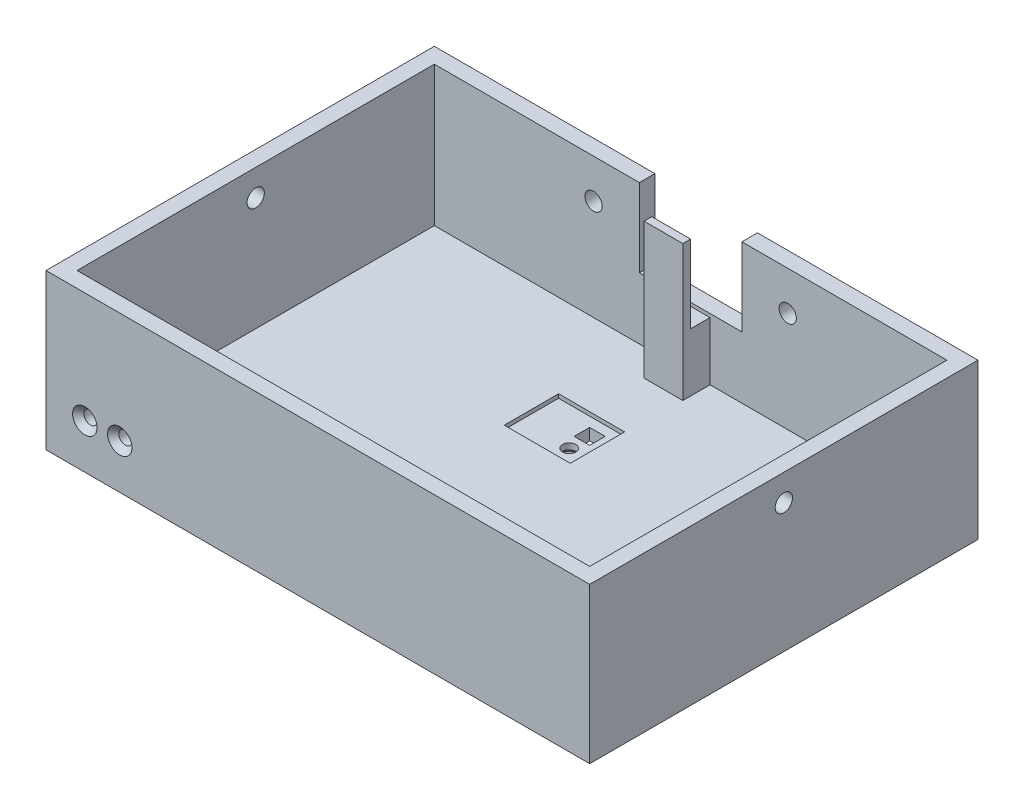
from build123d import *

# Parameters (mm, degrees)
SKETCH_1_W                  = 140
SKETCH_1_H                  = 100
SKETCH_1_W_2                = 132
SKETCH_1_H_2                = 92
EXTRUDE_2_DEPTH             = 4
EXTRUDE_3_DEPTH             = 2
EXTRUDE_START               = 4
SKETCH_1_6_W                = 140
SKETCH_1_6_H                = 100
SKETCH_1_6_W_2              = 132
SKETCH_1_6_H_2              = 92
EXTRUDE_4_DEPTH             = 36
HOLE_WIZARD_M31_D           = 3.4
HOLE_WIZARD_M31_DEPTH       = 4
HOLE_WIZARD_M31_CSINK_D     = 6.3
HOLE_WIZARD_M31_CSINK_ANGLE = 90
CUT_EXTRUDE_1_REACH         = 155.948
SKETCH_6_R                  = 2.225
CUT_EXTRUDE_3_REACH         = 130.452
SKETCH_7_W                  = 26.4
SKETCH_7_H                  = 20.1
CUT_EXTRUDE_6_REACH         = 130.452
SKETCH_7_9_R                = 2.225
HOLE_WIZARD_M33_D           = 3.4
HOLE_WIZARD_M33_CSINK_D     = 6.3
HOLE_WIZARD_M33_CSINK_ANGLE = 90
CUT_EXTRUDE_8_REACH         = 96.868
SKETCH_15_W                 = 4
SKETCH_15_H                 = 4
CUT_EXTRUDE_9_REACH         = 99.868
CUT_EXTRUDE_START           = -3
SKETCH_15_4_W               = 17
SKETCH_15_4_H               = 14
SKETCH_15_4_W_2             = 4
SKETCH_15_4_H_2             = 4
EXTRUDE_START_2             = -4
SKETCH_20_W                 = 10
SKETCH_20_H                 = 5
SKETCH_20_H_2               = 2
EXTRUDE_7_DEPTH             = 15
EXTRUDE_START_3             = -19
SKETCH_20_3_W               = 10
SKETCH_20_3_H               = 2
EXTRUDE_8_DEPTH             = 20
SKETCH_21_W                 = 0.664850428
SKETCH_21_H                 = 3.704166666
CUT_EXTRUDE_10_DEPTH        = 1


with BuildPart() as part:
    # Эскиз1 → Бобышка-Вытянуть2 (new body)
    with BuildSketch(Plane(origin=(0, 0, 0), x_dir=(1, 0, 0), z_dir=(0, 1, 0))):
        Rectangle(SKETCH_1_W, SKETCH_1_H)
        Rectangle(SKETCH_1_W_2, SKETCH_1_H_2, mode=Mode.SUBTRACT)
        Polygon((66, -46), (66, 46), (-66, 46), (-66, -46), (-63, -46), (-63, -44.5), (-59.7, -44.5), (-59.7, -41.5), (-51.3, -41.5), (-51.3, -44.5), (-48, -44.5), (-48, -46), align=None)
    extrude(amount=EXTRUDE_2_DEPTH)

    # Эскиз1<5> → Бобышка-Вытянуть3 (add)
    with BuildSketch(Plane(origin=(0, 0, 0), x_dir=(1, 0, 0), z_dir=(0, 1, 0))):
        Polygon((-63, -46), (-48, -46), (-48, -44.5), (-51.3, -44.5), (-51.3, -44.8), (-59.7, -44.8), (-59.7, -44.5), (-63, -44.5), align=None)
    extrude(amount=EXTRUDE_3_DEPTH)

    # Эскиз1<6> → Бобышка-Вытянуть4 (add)
    with BuildSketch(Plane(origin=(0, 0, 0), x_dir=(1, 0, 0), z_dir=(0, 1, 0)).offset(EXTRUDE_START)):
        Rectangle(SKETCH_1_6_W, SKETCH_1_6_H)
        Rectangle(SKETCH_1_6_W_2, SKETCH_1_6_H_2, mode=Mode.SUBTRACT)
    extrude(amount=EXTRUDE_4_DEPTH)

    # Зенковка для винта с потайной головкой M31
    with Locations(Plane(origin=(-51, 11.5, 50), x_dir=(1, 0, 0), z_dir=(0, 0, 1))):
        with Locations((0, 0), (-9, 0)):
            CounterSinkHole(HOLE_WIZARD_M31_D / 2, HOLE_WIZARD_M31_CSINK_D / 2, depth=HOLE_WIZARD_M31_DEPTH, counter_sink_angle=HOLE_WIZARD_M31_CSINK_ANGLE)

    # Эскиз6 → Вырез-Вытянуть1 (cut, up to next)
    with BuildSketch(Plane(origin=(70, 0, 0), x_dir=(0, 0, -1), z_dir=(1, 0, 0)), mode=Mode.PRIVATE) as cut_extrude_1_sk1:
        with Locations((0, 33.2)):
            Circle(SKETCH_6_R)
    cut_extrude_1_tool1 = extrude(cut_extrude_1_sk1.sketch, amount=-CUT_EXTRUDE_1_REACH, mode=Mode.PRIVATE) & part.part
    cut_extrude_1 = cut_extrude_1_tool1.solids().sort_by_distance((70, 33.2, 0))[0]
    add(cut_extrude_1, mode=Mode.SUBTRACT)

    # Зеркальное отражение1: Вырез-Вытянуть1 across plane
    add(cut_extrude_1.mirror(Plane(origin=(0, 0, 0), x_dir=(0, 0, 1), z_dir=(1, 0, 0))), mode=Mode.SUBTRACT)

    # Эскиз7 → Вырез-Вытянуть3 (cut, up to next)
    with BuildSketch(Plane(origin=(0, 0, -50), x_dir=(-1, 0, 0), z_dir=(0, 0, -1)), mode=Mode.PRIVATE) as cut_extrude_3_sk1:
        with Locations((0, 29.95)):
            Rectangle(SKETCH_7_W, SKETCH_7_H)
    cut_extrude_3_tool1 = extrude(cut_extrude_3_sk1.sketch, amount=-CUT_EXTRUDE_3_REACH, mode=Mode.PRIVATE) & part.part
    add(cut_extrude_3_tool1.solids().sort_by_distance((0, 29.95, -50))[0], mode=Mode.SUBTRACT)

    # Эскиз7<9> → Вырез-Вытянуть6 (cut, up to next)
    with BuildSketch(Plane(origin=(0, 0, -50), x_dir=(-1, 0, 0), z_dir=(0, 0, -1)), mode=Mode.PRIVATE) as cut_extrude_6_sk1:
        with Locations((-25, 29.95)):
            Circle(SKETCH_7_9_R)
    cut_extrude_6_tool1 = extrude(cut_extrude_6_sk1.sketch, amount=-CUT_EXTRUDE_6_REACH, mode=Mode.PRIVATE) & part.part
    # Эскиз7<9> → Вырез-Вытянуть6 (cut, up to next)
    with BuildSketch(Plane(origin=(0, 0, -50), x_dir=(-1, 0, 0), z_dir=(0, 0, -1)), mode=Mode.PRIVATE) as cut_extrude_6_sk2:
        with Locations((25, 29.95)):
            Circle(SKETCH_7_9_R)
    cut_extrude_6_tool2 = extrude(cut_extrude_6_sk2.sketch, amount=-CUT_EXTRUDE_6_REACH, mode=Mode.PRIVATE) & part.part
    add(cut_extrude_6_tool1.solids().sort_by_distance((25, 29.95, -50))[0], mode=Mode.SUBTRACT)
    add(cut_extrude_6_tool2.solids().sort_by_distance((-25, 29.95, -50))[0], mode=Mode.SUBTRACT)

    # Зенковка для винта с потайной головкой M33 (through all)
    with Locations(Plane(origin=(0, 0, -14.7), x_dir=(0, 0, -1), z_dir=(0, -1, 0))):
        with Locations((0, 0)):
            CounterSinkHole(HOLE_WIZARD_M33_D / 2, HOLE_WIZARD_M33_CSINK_D / 2, counter_sink_angle=HOLE_WIZARD_M33_CSINK_ANGLE)

    # Эскиз15 → Вырез-Вытянуть8 (cut, up to next)
    with BuildSketch(Plane.XZ, mode=Mode.PRIVATE) as cut_extrude_8_sk1:
        with Locations((0, -20)):
            Rectangle(SKETCH_15_W, SKETCH_15_H)
    cut_extrude_8_tool1 = extrude(cut_extrude_8_sk1.sketch, amount=-CUT_EXTRUDE_8_REACH, mode=Mode.PRIVATE) & part.part
    add(cut_extrude_8_tool1.solids().sort_by_distance((0, 0, -20))[0], mode=Mode.SUBTRACT)

    # Эскиз15<4> → Вырез-Вытянуть9 (cut, up to next)
    with BuildSketch(Plane.XZ.offset(CUT_EXTRUDE_START), mode=Mode.PRIVATE) as cut_extrude_9_sk1:
        with Locations((-4, -17.5)):
            Rectangle(SKETCH_15_4_W, SKETCH_15_4_H)
        with Locations((0, -20)):
            Rectangle(SKETCH_15_4_W_2, SKETCH_15_4_H_2, mode=Mode.SUBTRACT)
    cut_extrude_9_tool1 = extrude(cut_extrude_9_sk1.sketch, amount=-CUT_EXTRUDE_9_REACH, mode=Mode.PRIVATE) & part.part
    add(cut_extrude_9_tool1.solids().sort_by_distance((-4.288288, 3, -17.31982))[0], mode=Mode.SUBTRACT)

    # Эскиз20 → Бобышка-Вытянуть7 (add)
    with BuildSketch(Plane.XZ.offset(EXTRUDE_START_2)):
        with Locations((0, -43.5)):
            Rectangle(SKETCH_20_W, SKETCH_20_H)
        with Locations((0, -40)):
            Rectangle(SKETCH_20_W, SKETCH_20_H_2)
    extrude(amount=-EXTRUDE_7_DEPTH)

    # Эскиз20<3> → Бобышка-Вытянуть8 (add)
    with BuildSketch(Plane.XZ.offset(EXTRUDE_START_3)):
        with Locations((0, -40)):
            Rectangle(SKETCH_20_3_W, SKETCH_20_3_H)
    extrude(amount=-EXTRUDE_8_DEPTH)

    # Эскиз21 → Вырез-Вытянуть10 (cut)
    with BuildSketch(Plane.XZ):
        Polygon((-7.360844017, 26.295833333), (-8.100638522, 26.295833333), (-8.761778846, 27.595111345), (-9.422919171, 26.295833333), (-10.162713675, 26.295833333), (-9.09420406, 28.395751536), (-9.09420406, 30), (-8.429353632, 30), (-8.429353632, 28.395751536), align=None)
        with BuildLine():
            Line((-4.67769765, 30), (-4.67769765, 26.295833333))
            Line((-4.67769765, 26.295833333), (-5.271314103, 26.295833333))
            add(Edge.make_bspline(
                [(-5.271314103, 26.295833333), (-5.31287104, 26.29582766), (-5.393282926, 26.295816683), (-5.509295092, 26.299903172), (-5.616644377, 26.305119252), (-5.715461788, 26.311150817), (-5.805710741, 26.321160915), (-5.887453392, 26.331933671), (-5.960386991, 26.344839118), (-6.005477322, 26.356423188), (-6.026691039, 26.361873164)],
                knots=[0, 0, 0, 0, 1.311970222, 2.538637508, 3.664491357, 4.705491327, 5.663608299, 6.530571107, 7.308675535, 8, 8, 8, 8], degree=3))
            add(Edge.make_bspline(
                [(-6.026691039, 26.361873164), (-6.054546615, 26.369560182), (-6.109208197, 26.384644579), (-6.187505155, 26.415102656), (-6.261764836, 26.448979565), (-6.331971001, 26.48755156), (-6.397293339, 26.531538006), (-6.458627281, 26.580099943), (-6.515687524, 26.633253783), (-6.567564548, 26.691314468), (-6.614388963, 26.752752651), (-6.655239972, 26.817596967), (-6.690526167, 26.884819689), (-6.717620988, 26.955580973), (-6.740373771, 27.028032846), (-6.755595868, 27.103646953), (-6.765809559, 27.181771929), (-6.766750122, 27.234950154), (-6.767227564, 27.261944111)],
                knots=[0, 0, 0, 0, 1.099879008, 2.158315707, 3.195196496, 4.207130292, 5.205157476, 6.190838564, 7.183874245, 8.171129509, 9.152705923, 10.122275948, 11.08707516, 12.038677937, 13.004120747, 13.975884785, 14.972532894, 16, 16, 16, 16], degree=3))
            add(Edge.make_bspline(
                [(-6.767227564, 27.261944111), (-6.76606929, 27.296642989), (-6.763788001, 27.364984441), (-6.746281055, 27.464900878), (-6.718067585, 27.559857826), (-6.67819946, 27.650677442), (-6.624678653, 27.737222193), (-6.557936859, 27.821133851), (-6.476313973, 27.901266692), (-6.414743342, 27.950351077), (-6.382860911, 27.975767895)],
                knots=[0, 0, 0, 0, 0.986462413, 1.942894939, 2.875435142, 3.798266677, 4.755009598, 5.761362919, 6.840791609, 8, 8, 8, 8], degree=3))
            add(Edge.make_bspline(
                [(-6.382860911, 27.975767895), (-6.408979822, 27.989097155), (-6.460191781, 28.015232146), (-6.532852683, 28.058239537), (-6.600297973, 28.103797407), (-6.662059563, 28.151835509), (-6.719599834, 28.201400191), (-6.769346127, 28.255527376), (-6.816213212, 28.310039174), (-6.856337282, 28.368448582), (-6.891028514, 28.42950758), (-6.921804296, 28.492525813), (-6.946942144, 28.558756422), (-6.968581336, 28.627252077), (-6.984979225, 28.698720449), (-6.995584602, 28.772715956), (-7.003720801, 28.849195216), (-7.004352804, 28.901291794), (-7.004674145, 28.927780282)],
                knots=[0, 0, 0, 0, 1.164301211, 2.282872552, 3.350830854, 4.394111106, 5.389302619, 6.362088852, 7.310365691, 8.24222091, 9.170601078, 10.097577168, 11.024240953, 11.981127157, 12.948542686, 13.932080445, 14.948567018, 16, 16, 16, 16], degree=3))
            add(Edge.make_bspline(
                [(-7.004674145, 28.927780282), (-7.002692802, 28.978397696), (-6.998780658, 29.078341299), (-6.96712433, 29.224518762), (-6.916596092, 29.36381475), (-6.84574944, 29.493996255), (-6.759425249, 29.61275297), (-6.660581223, 29.717639041), (-6.549120308, 29.805474765), (-6.446974469, 29.865364426), (-6.358155382, 29.905297616), (-6.284285354, 29.929765961), (-6.20499898, 29.952445355), (-6.119408383, 29.970015998), (-6.027940433, 29.983108035), (-5.930636934, 29.992646338), (-5.827162295, 29.99866195), (-5.756109363, 29.999544966), (-5.719494525, 30)],
                knots=[0, 0, 0, 0, 1.284225818, 2.535691644, 3.779474941, 5.035581115, 6.285533147, 7.498311102, 8.683187976, 9.876672238, 10.49522506, 11.152635743, 11.850557634, 12.588370465, 13.369094102, 14.195874568, 15.07030211, 16, 16, 16, 16], degree=3))
            Line((-5.719494525, 30), (-4.67769765, 30))
        make_face()
        with BuildLine():
            Line((-5.342548077, 26.960683761), (-5.342548077, 27.768002137))
            Line((-5.342548077, 27.768002137), (-5.519148972, 27.768002137))
            add(Edge.make_bspline(
                [(-5.519148972, 27.768002137), (-5.543150918, 27.767793787), (-5.589485222, 27.767391581), (-5.656405391, 27.762174814), (-5.718647736, 27.753340305), (-5.776129913, 27.740752532), (-5.829187703, 27.725499305), (-5.877192725, 27.70609866), (-5.920300863, 27.682950654), (-5.97109283, 27.649311019), (-6.023411598, 27.597796057), (-6.070260271, 27.525078967), (-6.097716924, 27.440911558), (-6.100790162, 27.381609366), (-6.102377137, 27.350986579)],
                knots=[0, 0, 0, 0, 1.06517797, 2.056261606, 2.976983468, 3.853439442, 4.666321732, 5.424739265, 6.146762548, 6.834937974, 8.123729748, 9.372478121, 10.64318598, 12, 12, 12, 12], degree=3))
            add(Edge.make_bspline(
                [(-6.102377137, 27.350986579), (-6.101107736, 27.322301724), (-6.0986534, 27.266840711), (-6.07098899, 27.188915267), (-6.02789325, 27.120216444), (-5.977780501, 27.072519042), (-5.92999461, 27.040450445), (-5.888860674, 27.019067359), (-5.843656126, 27.000080932), (-5.793272027, 26.986822794), (-5.739218145, 26.974378655), (-5.680330231, 26.966811946), (-5.617204196, 26.961226635), (-5.57357826, 26.9608686), (-5.551055856, 26.960683761)],
                knots=[0, 0, 0, 0, 1.347812291, 2.605940898, 3.848830773, 5.144272192, 5.83350599, 6.558918059, 7.32804622, 8.140548749, 9.012446266, 9.943019774, 10.938059685, 12, 12, 12, 12], degree=3))
            Line((-5.551055856, 26.960683761), (-5.342548077, 26.960683761))
        make_face(mode=Mode.SUBTRACT)
        with BuildLine():
            Line((-5.342548077, 28.385363248), (-5.342548077, 29.335149573))
            Line((-5.342548077, 29.335149573), (-5.533989383, 29.335149573))
            add(Edge.make_bspline(
                [(-5.533989383, 29.335149573), (-5.571836642, 29.334929454), (-5.644602721, 29.334506248), (-5.748854794, 29.329534528), (-5.843594627, 29.320313304), (-5.928844514, 29.309547079), (-6.003906665, 29.292523899), (-6.070151968, 29.274824174), (-6.1264325, 29.252057352), (-6.17370873, 29.225655995), (-6.213247633, 29.195791329), (-6.247485595, 29.163470084), (-6.276042616, 29.127354439), (-6.299008818, 29.08824331), (-6.31830134, 29.046497592), (-6.330119516, 29.000731595), (-6.339075358, 28.952368581), (-6.339570425, 28.918921985), (-6.339823718, 28.901809562)],
                knots=[0, 0, 0, 0, 1.753677247, 3.371663338, 4.833688836, 6.164395063, 7.349095089, 8.3975697, 9.338276771, 10.154261968, 10.899224605, 11.628775934, 12.330426574, 13.024264642, 13.727131073, 14.452891561, 15.208446408, 16, 16, 16, 16], degree=3))
            add(Edge.make_bspline(
                [(-6.339823718, 28.901809562), (-6.339267862, 28.88224015), (-6.338185204, 28.844124201), (-6.329314979, 28.78842355), (-6.31326656, 28.73638578), (-6.292737226, 28.686661361), (-6.265021063, 28.640606417), (-6.231164445, 28.597914337), (-6.191468328, 28.558459282), (-6.145807334, 28.521643116), (-6.092791868, 28.488572661), (-6.031202431, 28.461825413), (-5.962630199, 28.437695864), (-5.885732735, 28.419043462), (-5.801112201, 28.403045041), (-5.708035099, 28.393532236), (-5.607311669, 28.386443148), (-5.537466849, 28.385731394), (-5.501340478, 28.385363248)],
                knots=[0, 0, 0, 0, 0.844862234, 1.645564352, 2.426138401, 3.19188377, 3.963047654, 4.738710309, 5.53926994, 6.37496817, 7.267116735, 8.227971149, 9.268346748, 10.402975021, 11.641070045, 12.984514716, 14.440277492, 16, 16, 16, 16], degree=3))
            Line((-5.501340478, 28.385363248), (-5.342548077, 28.385363248))
        make_face(mode=Mode.SUBTRACT)
        Polygon((-0.593616453, 26.295833333), (-2.588167735, 26.295833333), (-2.588167735, 26.960683761), (-1.25846688, 26.960683761), (-1.25846688, 27.673023504), (-2.588167735, 27.673023504), (-2.588167735, 28.337873932), (-1.25846688, 28.337873932), (-1.25846688, 29.335149573), (-2.588167735, 29.335149573), (-2.588167735, 30), (-0.593616453, 30), align=None)
        with BuildLine():
            Line((3.015571581, 26.295833333), (2.177830362, 26.295833333))
            add(Edge.make_bspline(
                [(2.177830362, 26.295833333), (2.112517208, 26.296279346), (1.986266142, 26.297141494), (1.803379182, 26.30722713), (1.633190412, 26.322037433), (1.476084825, 26.344703935), (1.331496675, 26.371011955), (1.200493246, 26.406243982), (1.082008378, 26.446675766), (0.974798578, 26.493784373), (0.877193779, 26.549031863), (0.785172007, 26.611100127), (0.697670919, 26.680920335), (0.614205601, 26.758655019), (0.534572647, 26.843787324), (0.460641374, 26.938031461), (0.390041599, 27.03894638), (0.323918809, 27.146882332), (0.265061267, 27.261626225), (0.212671457, 27.381372071), (0.169021282, 27.506197699), (0.13347976, 27.635930755), (0.105168974, 27.770195435), (0.085355478, 27.909247561), (0.073107843, 28.052962573), (0.07186533, 28.150365134), (0.071233974, 28.199858106)],
                knots=[0, 0, 0, 0, 1.44349102, 2.790284463, 4.047513061, 5.218094321, 6.297837468, 7.293772999, 8.213586047, 9.062895527, 9.878013142, 10.689252941, 11.514048747, 12.349645483, 13.208421871, 14.087867281, 14.994836234, 15.929653487, 16.883274053, 17.843080533, 18.816554169, 19.803369425, 20.81449504, 21.847452076, 22.906230055, 24, 24, 24, 24], degree=3))
            add(Edge.make_bspline(
                [(0.071233974, 28.199858106), (0.072887037, 28.269696003), (0.076141188, 28.407175991), (0.103555301, 28.608925044), (0.147885975, 28.802326415), (0.210244162, 28.985844916), (0.287464039, 29.157926595), (0.379944374, 29.315124356), (0.485028616, 29.457758629), (0.603649263, 29.583462816), (0.731883678, 29.69216878), (0.865667065, 29.784182979), (1.004879735, 29.858041143), (1.127803931, 29.904163618), (1.234694759, 29.933151783), (1.328404927, 29.949991966), (1.435055199, 29.965610546), (1.555047536, 29.979035128), (1.688737769, 29.988228315), (1.83571191, 29.994576859), (1.996005557, 29.999294231), (2.107334607, 29.999758579), (2.165216012, 30)],
                knots=[0, 0, 0, 0, 1.315347898, 2.589339334, 3.828278609, 5.048487211, 6.235212834, 7.375728391, 8.47833097, 9.56625089, 10.624194351, 11.640157642, 12.619895326, 13.585848527, 14.106971868, 14.704705962, 15.37825295, 16.137840974, 16.978850452, 17.902510282, 18.909488129, 20, 20, 20, 20], degree=3))
            Line((2.165216012, 30), (3.015571581, 30))
            Line((3.015571581, 30), (3.015571581, 26.295833333))
        make_face()
        with BuildLine():
            Line((2.350721154, 26.960683761), (2.350721154, 29.335149573))
            Line((2.350721154, 29.335149573), (2.003455529, 29.335149573))
            add(Edge.make_bspline(
                [(2.003455529, 29.335149573), (1.962143416, 29.334949523), (1.882698503, 29.334564818), (1.767857898, 29.329279022), (1.661875638, 29.320695518), (1.564612902, 29.307999222), (1.47584609, 29.292722328), (1.395898998, 29.273826825), (1.324614054, 29.250848453), (1.26140341, 29.22376821), (1.203693487, 29.192850105), (1.150229912, 29.156747291), (1.098631039, 29.116625617), (1.049850562, 29.071341384), (1.003706716, 29.021484388), (0.96047237, 28.966800313), (0.919567981, 28.907455897), (0.882054014, 28.843135016), (0.847741196, 28.774526831), (0.817426711, 28.702257198), (0.791835736, 28.625932135), (0.772401883, 28.545585428), (0.755846802, 28.461715662), (0.743892763, 28.37378358), (0.737380162, 28.282076463), (0.736520533, 28.219655142), (0.736084402, 28.187985777)],
                knots=[0, 0, 0, 0, 1.502729547, 2.8898115, 4.181010027, 5.369596896, 6.45687185, 7.456390247, 8.355533714, 9.177830239, 9.954819978, 10.733423081, 11.521791071, 12.330436719, 13.151797389, 13.990712567, 14.864234656, 15.771624029, 16.697123225, 17.652960569, 18.620374037, 19.622036587, 20.657870943, 21.729319508, 22.8479736, 24, 24, 24, 24], degree=3))
            add(Edge.make_bspline(
                [(0.736084402, 28.187985777), (0.736967187, 28.13945709), (0.73868855, 28.044829909), (0.75539277, 27.907021755), (0.782308144, 27.777417158), (0.821516404, 27.656349058), (0.869732311, 27.543047772), (0.931039844, 27.438973329), (1.001714565, 27.342419836), (1.057634518, 27.285788843), (1.085576088, 27.257491987)],
                knots=[0, 0, 0, 0, 1.138242922, 2.219485503, 3.251901297, 4.239342788, 5.201071, 6.134757343, 7.067992642, 8, 8, 8, 8], degree=3))
            add(Edge.make_bspline(
                [(1.085576088, 27.257491987), (1.113126827, 27.233378423), (1.169396092, 27.184129198), (1.268186429, 27.125116032), (1.377048264, 27.073267181), (1.49847203, 27.032156824), (1.631284219, 26.999645002), (1.776275864, 26.977222393), (1.932670503, 26.962813862), (2.041017064, 26.961409006), (2.09695012, 26.960683761)],
                knots=[0, 0, 0, 0, 0.813307809, 1.661089106, 2.549956539, 3.493439533, 4.508053171, 5.589449661, 6.755572447, 8, 8, 8, 8], degree=3))
            Line((2.09695012, 26.960683761), (2.350721154, 26.960683761))
        make_face(mode=Mode.SUBTRACT)
        Polygon((5.67423127, 26.295833333), (5.057612179, 26.295833333), (3.561698718, 30), (4.2718124, 30), (4.55971638, 29.24017094), (6.173611111, 29.24017094), (6.461515091, 30), (7.170886752, 30), align=None)
        Polygon((5.366292735, 27.289398872), (5.921324119, 28.575320513), (4.811261351, 28.575320513), align=None, mode=Mode.SUBTRACT)
        Polygon((11.128082432, 26.295833333), (10.438003305, 26.295833333), (9.59284188, 28.879548945), (8.741744291, 26.295833333), (8.058343349, 26.295833333), (7.432077991, 30), (8.105090645, 30), (8.500587607, 27.660409155), (9.270804955, 30), (9.919330929, 30), (10.685096154, 27.660409155), (11.079851095, 30), (11.753605769, 30), align=None)
        with Locations((-24.789423077, 35.369017094)):
            Rectangle(SKETCH_21_W, SKETCH_21_H)
        Polygon((-21.892574786, 33.516933761), (-23.887126068, 33.516933761), (-23.887126068, 34.181784188), (-22.557425214, 34.181784188), (-22.557425214, 34.894123932), (-23.887126068, 34.894123932), (-23.887126068, 35.558974359), (-22.557425214, 35.558974359), (-22.557425214, 36.55625), (-23.887126068, 36.55625), (-23.887126068, 37.221100427), (-21.892574786, 37.221100427), align=None)
        Polygon((-17.579209235, 33.516933761), (-18.269288361, 33.516933761), (-19.114449786, 36.100649372), (-19.965547376, 33.516933761), (-20.648948317, 33.516933761), (-21.275213675, 37.221100427), (-20.602201022, 37.221100427), (-20.20670406, 34.881509582), (-19.436486712, 37.221100427), (-18.787960737, 37.221100427), (-18.022195513, 34.881509582), (-17.627440572, 37.221100427), (-16.953685897, 37.221100427), align=None)
        with BuildLine():
            add(Edge.make_bspline(
                [(-14.705363582, 33.421955128), (-14.76976538, 33.423621928), (-14.896909117, 33.426912568), (-15.083886107, 33.454363303), (-15.264094619, 33.499038862), (-15.437560483, 33.561398748), (-15.603692097, 33.642160392), (-15.763099871, 33.740220734), (-15.915346963, 33.856411855), (-16.058658326, 33.989075704), (-16.190071338, 34.134139472), (-16.305584868, 34.288798347), (-16.403641213, 34.451455541), (-16.483233785, 34.622142746), (-16.545389843, 34.800625505), (-16.588587573, 34.986971553), (-16.616440445, 35.180942266), (-16.619636403, 35.313021049), (-16.621260684, 35.380147403)],
                knots=[0, 0, 0, 0, 1.014151002, 2.002163778, 2.969868608, 3.93493411, 4.9003771, 5.874719092, 6.87846472, 7.912488755, 8.947011879, 9.957751389, 10.948740761, 11.933621513, 12.919426746, 13.920294397, 14.943031967, 16, 16, 16, 16], degree=3))
            add(Edge.make_bspline(
                [(-16.621260684, 35.380147403), (-16.619530349, 35.446517269), (-16.616120669, 35.57730122), (-16.589728018, 35.769486236), (-16.545779498, 35.953829441), (-16.484821734, 36.130393858), (-16.406620854, 36.29918238), (-16.310062019, 36.459647309), (-16.195779624, 36.61211835), (-16.066108133, 36.755661408), (-15.924231793, 36.886803311), (-15.773065117, 37.001929792), (-15.614012522, 37.09876179), (-15.448090221, 37.179134426), (-15.273732924, 37.239532176), (-15.092873717, 37.28474007), (-14.903999662, 37.310881764), (-14.775686854, 37.314329205), (-14.710557726, 37.31607906)],
                knots=[0, 0, 0, 0, 1.051517626, 2.07204922, 3.067438659, 4.05042616, 5.027204762, 6.009981242, 7.012629434, 8.042243656, 9.071350414, 10.070091277, 11.048190212, 12.017682766, 12.985867053, 13.966945899, 14.968060614, 16, 16, 16, 16], degree=3))
            add(Edge.make_bspline(
                [(-14.710557726, 37.31607906), (-14.642435195, 37.314527756), (-14.508583734, 37.311479655), (-14.312642895, 37.282738127), (-14.125182194, 37.238917841), (-13.946715278, 37.17547661), (-13.777380883, 37.093043563), (-13.616419618, 36.99351195), (-13.465042054, 36.87495918), (-13.323752777, 36.740961007), (-13.195759261, 36.594299591), (-13.082775979, 36.439374679), (-12.987473054, 36.277357875), (-12.909845588, 36.108176448), (-12.848647277, 35.932881011), (-12.805478806, 35.750404179), (-12.779978163, 35.56118354), (-12.776426072, 35.432661101), (-12.774626068, 35.367533053)],
                knots=[0, 0, 0, 0, 1.067953136, 2.098381936, 3.099641766, 4.083805132, 5.062469929, 6.048665414, 7.046702845, 8.073106546, 9.098695993, 10.09591865, 11.076726721, 12.041940862, 13.011263376, 13.984305721, 14.978557872, 16, 16, 16, 16], degree=3))
            add(Edge.make_bspline(
                [(-12.774626068, 35.367533053), (-12.775198807, 35.323720211), (-12.776337033, 35.2366493), (-12.789747111, 35.10758116), (-12.809635896, 34.981217252), (-12.836863166, 34.857319954), (-12.873547352, 34.736208555), (-12.918134, 34.61757756), (-12.970091499, 34.501427624), (-13.030007529, 34.388809159), (-13.097784513, 34.281069585), (-13.170152046, 34.177267897), (-13.249881955, 34.080129095), (-13.335328582, 33.988598012), (-13.426826612, 33.903093059), (-13.524535401, 33.823322272), (-13.628301155, 33.749489113), (-13.737001511, 33.680983463), (-13.850264629, 33.620983157), (-13.965395767, 33.566597273), (-14.08350017, 33.522501213), (-14.20372032, 33.485979468), (-14.325779821, 33.456669284), (-14.450621079, 33.43718051), (-14.577190461, 33.423664491), (-14.662537815, 33.422526268), (-14.705363582, 33.421955128)],
                knots=[0, 0, 0, 0, 1.034641744, 2.056182551, 3.061960284, 4.05571729, 5.050247014, 6.048716841, 7.047801973, 8.054190544, 9.059424999, 10.053182006, 11.041513076, 12.025412457, 13.009311837, 13.997642908, 15.002928308, 16.016213968, 17.030509951, 18.02913364, 19.022134519, 20.005478534, 20.996155877, 21.984625117, 22.988721131, 24, 24, 24, 24], degree=3))
        make_face()
        with BuildLine():
            add(Edge.make_bspline(
                [(-14.694975294, 34.086805556), (-14.65163311, 34.087968525), (-14.566092984, 34.090263762), (-14.440621161, 34.107750318), (-14.320163918, 34.135678445), (-14.205388349, 34.176131607), (-14.0957994, 34.227619602), (-13.991193856, 34.289956296), (-13.893054206, 34.365308271), (-13.79994102, 34.449540014), (-13.71611224, 34.543781234), (-13.640738811, 34.643676397), (-13.579796335, 34.75162915), (-13.527394505, 34.864083821), (-13.488687649, 34.983884269), (-13.459216415, 35.109086142), (-13.443164433, 35.240974728), (-13.440723322, 35.330639804), (-13.439476496, 35.3764373)],
                knots=[0, 0, 0, 0, 1.033668485, 2.040047952, 3.016132939, 3.979056467, 4.937231767, 5.900589077, 6.877725736, 7.88429546, 8.891280164, 9.882584218, 10.863295226, 11.842887319, 12.837417301, 13.860812229, 14.907384602, 16, 16, 16, 16], degree=3))
            add(Edge.make_bspline(
                [(-13.439476496, 35.3764373), (-13.440992074, 35.427205361), (-13.443962357, 35.526702348), (-13.464557583, 35.671923679), (-13.500644433, 35.808913024), (-13.54994342, 35.938128658), (-13.615475835, 36.058211804), (-13.693854083, 36.17061827), (-13.787040584, 36.274650631), (-13.85870455, 36.335439662), (-13.895077123, 36.366292735)],
                knots=[0, 0, 0, 0, 1.078343132, 2.113373867, 3.107373148, 4.082093053, 5.043582658, 6.005574554, 6.987742499, 8, 8, 8, 8], degree=3))
            add(Edge.make_bspline(
                [(-13.895077123, 36.366292735), (-13.924881143, 36.389082186), (-13.983817693, 36.434147638), (-14.077893258, 36.491908259), (-14.174772566, 36.541414873), (-14.275186692, 36.581415632), (-14.378923567, 36.612879556), (-14.485968966, 36.634913225), (-14.596171214, 36.648741258), (-14.670695139, 36.65039397), (-14.708331664, 36.651228632)],
                knots=[0, 0, 0, 0, 1.023928204, 2.024787132, 3.009472467, 3.9914905, 4.972207045, 5.96565515, 6.972602802, 8, 8, 8, 8], degree=3))
            add(Edge.make_bspline(
                [(-14.708331664, 36.651228632), (-14.750927753, 36.650054138), (-14.834736898, 36.647743284), (-14.957884769, 36.630495759), (-15.075809444, 36.601178982), (-15.189603962, 36.561367862), (-15.297744529, 36.508014065), (-15.401917515, 36.444660522), (-15.500881357, 36.369331374), (-15.593429624, 36.28297692), (-15.678245163, 36.188731256), (-15.753283311, 36.08829577), (-15.815427269, 35.981666554), (-15.867263239, 35.870267945), (-15.907649232, 35.753212974), (-15.935287587, 35.630492815), (-15.953050228, 35.502602587), (-15.955276241, 35.41557718), (-15.956410256, 35.371243156)],
                knots=[0, 0, 0, 0, 1.026350473, 2.019376834, 2.989435443, 3.95094063, 4.91865229, 5.889827372, 6.885283771, 7.910196595, 8.935871797, 9.9372888, 10.925850568, 11.904605667, 12.894245083, 13.903507864, 14.931967858, 16, 16, 16, 16], degree=3))
            add(Edge.make_bspline(
                [(-15.956410256, 35.371243156), (-15.955241397, 35.327162246), (-15.952940676, 35.240395697), (-15.935596497, 35.112860252), (-15.906762389, 34.9908144), (-15.866010578, 34.873943537), (-15.815242302, 34.761634101), (-15.751468895, 34.654860841), (-15.676072678, 34.553716135), (-15.590431958, 34.458801301), (-15.49723263, 34.371574801), (-15.397169797, 34.295879545), (-15.293048117, 34.230102387), (-15.182477277, 34.178575311), (-15.06771979, 34.137523774), (-14.948075311, 34.107292839), (-14.823090705, 34.090386601), (-14.738061092, 34.088009878), (-14.694975294, 34.086805556)],
                knots=[0, 0, 0, 0, 1.055040155, 2.076685641, 3.074845078, 4.052329834, 5.035358467, 6.020382375, 7.023447318, 8.050688466, 9.077178457, 10.074336316, 11.0503314, 12.019748348, 12.988025369, 13.964577102, 14.968620271, 16, 16, 16, 16], degree=3))
        make_face(mode=Mode.SUBTRACT)
        Polygon((-10.495138889, 33.516933761), (-12.299732906, 33.516933761), (-12.299732906, 34.181784188), (-11.159989316, 34.181784188), (-11.159989316, 34.894123932), (-12.299732906, 34.894123932), (-12.299732906, 35.558974359), (-11.159989316, 35.558974359), (-11.159989316, 37.221100427), (-10.495138889, 37.221100427), align=None)
        with Locations((-9.307905983, 35.369017094)):
            Rectangle(SKETCH_21_W, SKETCH_21_H)
        Polygon((-6.553525641, 33.516933761), (-8.548076923, 33.516933761), (-8.548076923, 34.181784188), (-7.883226496, 34.181784188), (-7.883226496, 37.221100427), (-7.218376068, 37.221100427), (-7.218376068, 34.181784188), (-6.553525641, 34.181784188), align=None)
        with BuildLine():
            Line((-4.331916066, 35.754867788), (-4.748931624, 36.22827691))
            Line((-4.748931624, 36.22827691), (-4.558232338, 36.400425681))
            Line((-4.558232338, 36.400425681), (-4.369759115, 36.56960637))
            Line((-4.369759115, 36.56960637), (-4.962633547, 37.221100427))
            Line((-4.962633547, 37.221100427), (-4.11450404, 37.221100427))
            Line((-4.11450404, 37.221100427), (-3.872605335, 36.970297476))
            add(Edge.make_bspline(
                [(-3.872605335, 36.970297476), (-3.824823584, 36.993973181), (-3.731173812, 37.040376342), (-3.59012685, 37.101357759), (-3.451603407, 37.152619091), (-3.315922255, 37.195714531), (-3.181994097, 37.226968032), (-3.051146983, 37.251392421), (-2.922661039, 37.266034907), (-2.837769151, 37.267746334), (-2.795933494, 37.268589744)],
                knots=[0, 0, 0, 0, 1.134846175, 2.224240057, 3.268605059, 4.277623426, 5.251861872, 6.193569972, 7.109771376, 8, 8, 8, 8], degree=3))
            add(Edge.make_bspline(
                [(-2.795933494, 37.268589744), (-2.761526026, 37.267890707), (-2.694254804, 37.266523996), (-2.595857848, 37.255455057), (-2.502585165, 37.235919093), (-2.414229797, 37.209592751), (-2.331116956, 37.174948556), (-2.252699388, 37.133562708), (-2.179760621, 37.083469128), (-2.112507044, 37.026203326), (-2.050867996, 36.963951496), (-1.99831595, 36.895613508), (-1.952158379, 36.824425645), (-1.915932013, 36.747592991), (-1.886605088, 36.666985612), (-1.867235261, 36.581682902), (-1.853615766, 36.492627103), (-1.852602225, 36.431645659), (-1.852083333, 36.400425681)],
                knots=[0, 0, 0, 0, 1.146325904, 2.24122114, 3.293472846, 4.31812184, 5.308385844, 6.289138462, 7.267533498, 8.249981455, 9.229105173, 10.180360779, 11.117770178, 12.050384985, 13.00449251, 13.970029, 14.960738752, 16, 16, 16, 16], degree=3))
            add(Edge.make_bspline(
                [(-1.852083333, 36.400425681), (-1.853958588, 36.353038567), (-1.857693425, 36.258660348), (-1.887269611, 36.119438589), (-1.933919206, 35.983957512), (-1.989794753, 35.875716832), (-2.04338222, 35.790353753), (-2.091430023, 35.725744027), (-2.14543336, 35.660371755), (-2.207045857, 35.595149943), (-2.274129221, 35.528013928), (-2.349551491, 35.461930849), (-2.430131323, 35.393894624), (-2.487537974, 35.350451535), (-2.516933761, 35.328205963)],
                knots=[0, 0, 0, 0, 1.298575957, 2.586299866, 3.886292323, 5.218034109, 5.916202773, 6.6488126, 7.424377237, 8.240272888, 9.10843449, 10.02606486, 10.989222055, 12, 12, 12, 12], degree=3))
            add(Edge.make_bspline(
                [(-2.516933761, 35.328205963), (-2.486789799, 35.289966278), (-2.428437931, 35.215942927), (-2.351393476, 35.103003213), (-2.285634756, 34.993908571), (-2.231595265, 34.888214102), (-2.189696947, 34.785714894), (-2.159607732, 34.686422268), (-2.140716331, 34.590367358), (-2.138229023, 34.527149308), (-2.137019231, 34.496400908)],
                knots=[0, 0, 0, 0, 1.254783331, 2.428975762, 3.521264868, 4.536304978, 5.485798762, 6.371253184, 7.2077997, 8, 8, 8, 8], degree=3))
            add(Edge.make_bspline(
                [(-2.137019231, 34.496400908), (-2.137746568, 34.474096711), (-2.139210139, 34.429215472), (-2.150760555, 34.362258673), (-2.16969221, 34.295488472), (-2.195560044, 34.228783949), (-2.229358574, 34.162741125), (-2.269874432, 34.096624052), (-2.318160203, 34.031000724), (-2.373030478, 33.966114606), (-2.434905213, 33.90541779), (-2.503208763, 33.851552183), (-2.578194158, 33.806825223), (-2.659205845, 33.770396509), (-2.745861055, 33.741242638), (-2.839033793, 33.721769428), (-2.937767941, 33.708449123), (-3.00587808, 33.707419134), (-3.04080028, 33.706891026)],
                knots=[0, 0, 0, 0, 0.803898129, 1.617630241, 2.442092495, 3.303311795, 4.192745454, 5.11355102, 6.096443408, 7.127633651, 8.174554725, 9.216449452, 10.256510395, 11.314202351, 12.414104221, 13.545904242, 14.741708296, 16, 16, 16, 16], degree=3))
            add(Edge.make_bspline(
                [(-3.04080028, 33.706891026), (-3.075967573, 33.707424675), (-3.144566181, 33.708465632), (-3.244065787, 33.721715057), (-3.337576594, 33.741378673), (-3.424798886, 33.769405562), (-3.505384142, 33.80628261), (-3.580521906, 33.849777441), (-3.648161585, 33.90322545), (-3.709292712, 33.963154486), (-3.763315804, 34.026968145), (-3.810469649, 34.092099365), (-3.850817871, 34.157154233), (-3.883196023, 34.222714391), (-3.910273867, 34.287526425), (-3.92757484, 34.353505045), (-3.939451022, 34.419297827), (-3.94089822, 34.463454031), (-3.941613248, 34.4852706)],
                knots=[0, 0, 0, 0, 1.276613589, 2.490209188, 3.639193385, 4.744453696, 5.809999019, 6.853188294, 7.890207437, 8.932196598, 9.958377908, 10.92346682, 11.851109371, 12.735083872, 13.577633109, 14.397160969, 15.208073967, 16, 16, 16, 16], degree=3))
            add(Edge.make_bspline(
                [(-3.941613248, 34.4852706), (-3.940380217, 34.519511989), (-3.937928421, 34.587598587), (-3.916497154, 34.688199145), (-3.884123963, 34.786956173), (-3.844410872, 34.867749035), (-3.803253851, 34.934037485), (-3.763489369, 34.990135026), (-3.714423414, 35.051116728), (-3.656981624, 35.117924754), (-3.591602805, 35.190832952), (-3.517213385, 35.269346112), (-3.434334533, 35.353951633), (-3.3750995, 35.411209014), (-3.344286692, 35.440993089)],
                knots=[0, 0, 0, 0, 1.060773976, 2.109274582, 3.176545833, 4.277732972, 4.890795241, 5.595227009, 6.408622695, 7.317144787, 8.327436618, 9.445222173, 10.671058765, 12, 12, 12, 12], degree=3))
            add(Edge.make_bspline(
                [(-3.344286692, 35.440993089), (-3.380127531, 35.482566595), (-3.448253538, 35.561589214), (-3.545471268, 35.673623204), (-3.632436444, 35.77339038), (-3.709708591, 35.860856683), (-3.776570562, 35.936657197), (-3.83489443, 35.998853547), (-3.882218753, 36.049468984), (-3.910664968, 36.078912642), (-3.923062734, 36.091745126)],
                knots=[0, 0, 0, 0, 1.51243447, 2.87482453, 4.087181207, 5.159139051, 6.090728175, 6.871952111, 7.508360801, 8, 8, 8, 8], degree=3))
            add(Edge.make_bspline(
                [(-3.923062734, 36.091745126), (-3.930955974, 36.085533912), (-3.949385096, 36.071031984), (-3.981689176, 36.04687022), (-4.020643574, 36.014426087), (-4.068443056, 35.976276278), (-4.122738975, 35.930021291), (-4.185711242, 35.878059818), (-4.255890071, 35.818571113), (-4.305675984, 35.776854748), (-4.331916066, 35.754867788)],
                knots=[0, 0, 0, 0, 0.454982147, 1.062291435, 1.826978546, 2.750907302, 3.832570326, 5.057685674, 6.44922862, 8, 8, 8, 8], degree=3))
        make_face()
        with BuildLine():
            add(Edge.make_bspline(
                [(-2.9873748, 34.952743556), (-3.010088905, 34.933684727), (-3.053714991, 34.897079188), (-3.112855887, 34.841017678), (-3.163318436, 34.786946923), (-3.203636537, 34.733727366), (-3.236128459, 34.682634124), (-3.25950791, 34.632919711), (-3.273954816, 34.584517037), (-3.275847362, 34.552634289), (-3.276762821, 34.537212039)],
                knots=[0, 0, 0, 0, 1.365108641, 2.621910227, 3.750473504, 4.766462676, 5.692471511, 6.533310132, 7.290536163, 8, 8, 8, 8], degree=3))
            add(Edge.make_bspline(
                [(-3.276762821, 34.537212039), (-3.275865302, 34.522047131), (-3.274143095, 34.492947902), (-3.262007075, 34.451147055), (-3.2406074, 34.414548646), (-3.212227166, 34.382040412), (-3.17650848, 34.356422471), (-3.135300529, 34.337297871), (-3.088862358, 34.326231074), (-3.056194244, 34.324926266), (-3.039316239, 34.324252137)],
                knots=[0, 0, 0, 0, 1.016660416, 1.95082179, 2.886895472, 3.838707486, 4.824036216, 5.811038779, 6.869071653, 8, 8, 8, 8], degree=3))
            add(Edge.make_bspline(
                [(-3.039316239, 34.324252137), (-3.023403643, 34.325139362), (-2.992053444, 34.326887329), (-2.947073113, 34.339762429), (-2.906025436, 34.36106331), (-2.870022284, 34.390041), (-2.839734174, 34.424260727), (-2.817794662, 34.462658991), (-2.804469215, 34.503950905), (-2.802744665, 34.532415747), (-2.801869658, 34.546858307)],
                knots=[0, 0, 0, 0, 1.057994133, 2.084406969, 3.085568065, 4.116326501, 5.142871292, 6.108496369, 7.040284384, 8, 8, 8, 8], degree=3))
            add(Edge.make_bspline(
                [(-2.801869658, 34.546858307), (-2.8024565, 34.561989738), (-2.803658999, 34.592995587), (-2.813323016, 34.639916144), (-2.827523908, 34.688611607), (-2.847333395, 34.739092841), (-2.874989957, 34.790258926), (-2.906510886, 34.843514386), (-2.944070783, 34.898389132), (-2.97254283, 34.934126735), (-2.9873748, 34.952743556)],
                knots=[0, 0, 0, 0, 0.798403377, 1.636010132, 2.52046941, 3.476032658, 4.492491044, 5.587786094, 6.743403203, 8, 8, 8, 8], degree=3))
        make_face(mode=Mode.SUBTRACT)
        with BuildLine():
            add(Edge.make_bspline(
                [(-3.437781283, 36.476853799), (-3.419693129, 36.459326568), (-3.381257762, 36.422083102), (-3.321025205, 36.362317554), (-3.256629586, 36.29339988), (-3.186058175, 36.217264598), (-3.110684325, 36.132626323), (-3.029628911, 36.040304522), (-2.942762805, 35.940588992), (-2.884110318, 35.870480997), (-2.853811098, 35.834263989)],
                knots=[0, 0, 0, 0, 0.695851971, 1.478609945, 2.343846541, 3.301331317, 4.346617988, 5.474767113, 6.695492858, 8, 8, 8, 8], degree=3))
            add(Edge.make_bspline(
                [(-2.853811098, 35.834263989), (-2.827339971, 35.858983628), (-2.776442551, 35.90651337), (-2.707485847, 35.978827942), (-2.649087469, 36.048879343), (-2.600897119, 36.116186848), (-2.564325152, 36.182131517), (-2.536810817, 36.245178449), (-2.520310602, 36.306589129), (-2.51802983, 36.346913892), (-2.516933761, 36.366292735)],
                knots=[0, 0, 0, 0, 1.344929586, 2.585966416, 3.70798992, 4.729929545, 5.655146471, 6.503081986, 7.280627179, 8, 8, 8, 8], degree=3))
            add(Edge.make_bspline(
                [(-2.516933761, 36.366292735), (-2.518319407, 36.384011948), (-2.521089616, 36.419436531), (-2.540984809, 36.471359643), (-2.574604235, 36.519428516), (-2.619127014, 36.564117411), (-2.672162443, 36.603712485), (-2.734888478, 36.631072085), (-2.803601178, 36.648889336), (-2.851962217, 36.650434574), (-2.876813735, 36.651228632)],
                knots=[0, 0, 0, 0, 0.839037447, 1.677419396, 2.597629847, 3.600735691, 4.658333153, 5.713002508, 6.824769699, 8, 8, 8, 8], degree=3))
            add(Edge.make_bspline(
                [(-2.876813735, 36.651228632), (-2.896134324, 36.650583215), (-2.935921347, 36.649254103), (-2.997371842, 36.6403633), (-3.062455236, 36.627361052), (-3.130888555, 36.607451482), (-3.202743293, 36.583075914), (-3.278219773, 36.552991581), (-3.357194383, 36.517588076), (-3.410432869, 36.490677607), (-3.437781283, 36.476853799)],
                knots=[0, 0, 0, 0, 0.782485555, 1.611377918, 2.511278134, 3.469099476, 4.495613048, 5.58396865, 6.758893619, 8, 8, 8, 8], degree=3))
        make_face(mode=Mode.SUBTRACT)
        with BuildLine():
            Line((1.314860443, 37.31607906), (1.904024773, 37.019270833))
            Line((1.904024773, 37.019270833), (1.25846688, 35.748931624))
            add(Edge.make_bspline(
                [(1.25846688, 35.748931624), (1.296607864, 35.747959386), (1.371487844, 35.746050648), (1.481743772, 35.730191295), (1.587174987, 35.703112703), (1.689042542, 35.667083721), (1.785869493, 35.618710401), (1.879219358, 35.561167552), (1.966654697, 35.490975859), (2.050269542, 35.413256118), (2.125905575, 35.327119158), (2.192704846, 35.235083382), (2.249267826, 35.138034615), (2.294674208, 35.035320704), (2.330336574, 34.92796528), (2.356639511, 34.815547213), (2.371355685, 34.697634096), (2.373416635, 34.617389564), (2.374465812, 34.576539129)],
                knots=[0, 0, 0, 0, 1.014438208, 1.991587644, 2.955575466, 3.906834206, 4.860343588, 5.829907848, 6.818577787, 7.838125475, 8.863876483, 9.862937823, 10.859547262, 11.846397878, 12.845242478, 13.865236027, 14.913246352, 16, 16, 16, 16], degree=3))
            add(Edge.make_bspline(
                [(2.374465812, 34.576539129), (2.373494963, 34.536913393), (2.371581926, 34.458831699), (2.355651941, 34.34424573), (2.329539481, 34.23417815), (2.293278159, 34.128663242), (2.246338904, 34.027884756), (2.18837805, 33.932266081), (2.120953697, 33.84074871), (2.04320093, 33.755477974), (1.959039408, 33.677399776), (1.869077631, 33.609451961), (1.775637548, 33.55085372), (1.676716567, 33.50429898), (1.574122279, 33.466508387), (1.466496569, 33.440943187), (1.354924878, 33.42483521), (1.279052001, 33.422922837), (1.240658387, 33.421955128)],
                knots=[0, 0, 0, 0, 1.05547428, 2.079790231, 3.075662031, 4.065650429, 5.047466705, 6.031911617, 7.04026589, 8.071428158, 9.102169131, 10.094698886, 11.071325611, 12.035261792, 13.002593907, 13.979242867, 14.977445265, 16, 16, 16, 16], degree=3))
            add(Edge.make_bspline(
                [(1.240658387, 33.421955128), (1.200522348, 33.422781626), (1.121600258, 33.424406822), (1.00606522, 33.442328131), (0.895540183, 33.469847591), (0.789509066, 33.50713643), (0.689653926, 33.558011332), (0.594072109, 33.617777201), (0.504616041, 33.690151384), (0.420827081, 33.771573449), (0.345395384, 33.860889793), (0.278143759, 33.953609789), (0.220977716, 34.050019117), (0.175313598, 34.150184914), (0.139004495, 34.253418931), (0.114264302, 34.35994954), (0.097795997, 34.469672024), (0.095925363, 34.544076886), (0.094978632, 34.581733273)],
                knots=[0, 0, 0, 0, 1.062709067, 2.08967359, 3.089490552, 4.078335371, 5.060205664, 6.052952122, 7.060109841, 8.102908433, 9.144326257, 10.153805576, 11.135063239, 12.108674621, 13.066249871, 14.029571809, 15.002763993, 16, 16, 16, 16], degree=3))
            add(Edge.make_bspline(
                [(0.094978632, 34.581733273), (0.095498592, 34.610452263), (0.096545909, 34.668298766), (0.106715372, 34.75480974), (0.122357037, 34.841542993), (0.140598701, 34.914599297), (0.158947416, 34.976431057), (0.178027013, 35.028736249), (0.2010379, 35.087020853), (0.22767169, 35.151374564), (0.258142365, 35.221478582), (0.293488558, 35.297089278), (0.331477788, 35.379365249), (0.359484205, 35.435622786), (0.373978365, 35.464737747)],
                knots=[0, 0, 0, 0, 1.105166677, 2.22605417, 3.348517788, 4.496260522, 5.122810462, 5.830557215, 6.638607343, 7.535109037, 8.511576286, 9.580928918, 10.748058253, 12, 12, 12, 12], degree=3))
            Line((0.373978365, 35.464737747), (1.314860443, 37.31607906))
        make_face()
        with BuildLine():
            add(Edge.make_bspline(
                [(1.225817975, 35.131570513), (1.193958457, 35.129697993), (1.13171217, 35.126039514), (1.042344582, 35.097663982), (0.962043155, 35.049253924), (0.891604658, 34.984042078), (0.832967623, 34.905645114), (0.790001492, 34.816571813), (0.763952075, 34.718240743), (0.761229798, 34.649666701), (0.75982906, 34.614382178)],
                knots=[0, 0, 0, 0, 0.984989413, 1.924446292, 2.868477643, 3.865502828, 4.877610339, 5.88087679, 6.909612885, 8, 8, 8, 8], degree=3))
            add(Edge.make_bspline(
                [(0.75982906, 34.614382178), (0.761485122, 34.578350566), (0.76470656, 34.508260476), (0.791438257, 34.407634855), (0.835669685, 34.316102283), (0.897449901, 34.236767309), (0.970003108, 34.170917798), (1.050450083, 34.12221784), (1.137455724, 34.092300095), (1.197639428, 34.088649715), (1.228044037, 34.086805556)],
                knots=[0, 0, 0, 0, 1.10379546, 2.14714571, 3.168417875, 4.20176326, 5.211701457, 6.157576563, 7.069213742, 8, 8, 8, 8], degree=3))
            add(Edge.make_bspline(
                [(1.228044037, 34.086805556), (1.260178968, 34.088604332), (1.323275643, 34.092136216), (1.413840067, 34.121970289), (1.496948135, 34.169603772), (1.570624772, 34.235333308), (1.632910283, 34.314252583), (1.677198538, 34.405710907), (1.704957625, 34.50591414), (1.708034882, 34.576105362), (1.709615385, 34.612156116)],
                knots=[0, 0, 0, 0, 0.970853505, 1.906262912, 2.855477211, 3.852937491, 4.877462982, 5.878766514, 6.910518104, 8, 8, 8, 8], degree=3))
            add(Edge.make_bspline(
                [(1.709615385, 34.612156116), (1.707869301, 34.64766811), (1.704476449, 34.716672205), (1.679032341, 34.81616509), (1.63425699, 34.905553249), (1.574047989, 34.984351851), (1.501232902, 35.049548777), (1.417668418, 35.098044439), (1.324265107, 35.125979741), (1.259143995, 35.129677942), (1.225817975, 35.131570513)],
                knots=[0, 0, 0, 0, 1.075564157, 2.089951178, 3.085472164, 4.085356838, 5.078137244, 6.028240785, 6.99094342, 8, 8, 8, 8], degree=3))
        make_face(mode=Mode.SUBTRACT)
        Polygon((4.684375835, 33.516933761), (3.65667735, 33.516933761), (3.65667735, 37.221100427), (4.321527778, 37.221100427), (4.321527778, 34.134294872), (5.081356838, 34.134294872), align=None)
        with BuildLine():
            Line((8.073183761, 33.516933761), (7.29851429, 33.516933761))
            add(Edge.make_bspline(
                [(7.29851429, 33.516933761), (7.247308418, 33.517112294), (7.148825103, 33.517455665), (7.006824834, 33.523013308), (6.876352274, 33.53054503), (6.757117557, 33.542745021), (6.64925657, 33.556763825), (6.552989269, 33.575583129), (6.467957625, 33.596460001), (6.393115644, 33.62215008), (6.325738748, 33.651687951), (6.26318074, 33.685126507), (6.2038786, 33.723375728), (6.14826415, 33.766312818), (6.094625968, 33.812307107), (6.045835794, 33.864031764), (5.999717074, 33.919793839), (5.956754206, 33.979596943), (5.918179701, 34.043301477), (5.884916934, 34.110145867), (5.85627669, 34.17972464), (5.833610819, 34.252292032), (5.815534654, 34.327641455), (5.803446962, 34.405585961), (5.794465838, 34.486299811), (5.793956434, 34.541142881), (5.793696581, 34.569118924)],
                knots=[0, 0, 0, 0, 1.748592178, 3.36303531, 4.852592433, 6.210838904, 7.455605234, 8.565530618, 9.559147328, 10.443333557, 11.264119507, 12.069061813, 12.863340979, 13.67089394, 14.467102114, 15.273638367, 16.095597024, 16.937114566, 17.786018611, 18.63597263, 19.484582448, 20.352808207, 21.22970172, 22.128176732, 23.04516274, 24, 24, 24, 24], degree=3))
            add(Edge.make_bspline(
                [(5.793696581, 34.569118924), (5.794380536, 34.598317963), (5.795721647, 34.655571958), (5.80288571, 34.739684459), (5.816204546, 34.820352531), (5.835720476, 34.897058496), (5.859079899, 34.970587954), (5.889332602, 35.039793301), (5.923734583, 35.105898771), (5.96454649, 35.167815005), (6.009363771, 35.226872604), (6.061413731, 35.280926618), (6.11775534, 35.332539425), (6.180103109, 35.379953429), (6.248270374, 35.422873468), (6.320975319, 35.463042894), (6.399222724, 35.499748228), (6.454185317, 35.520278807), (6.482291667, 35.530777577)],
                knots=[0, 0, 0, 0, 1.099808295, 2.156523617, 3.176426857, 4.17500812, 5.135317955, 6.078349783, 7.015890908, 7.9382699, 8.868004242, 9.803692517, 10.759882289, 11.743580734, 12.748787378, 13.791075452, 14.870417076, 16, 16, 16, 16], degree=3))
            Line((6.482291667, 35.530777577), (5.627483974, 37.221100427))
            Line((5.627483974, 37.221100427), (6.366536458, 37.221100427))
            Line((6.366536458, 37.221100427), (7.182759081, 35.606463675))
            Line((7.182759081, 35.606463675), (7.408333333, 35.606463675))
            Line((7.408333333, 35.606463675), (7.408333333, 37.221100427))
            Line((7.408333333, 37.221100427), (8.073183761, 37.221100427))
            Line((8.073183761, 37.221100427), (8.073183761, 33.516933761))
        make_face()
        with BuildLine():
            Line((7.408333333, 34.941613248), (7.149368156, 34.941613248))
            add(Edge.make_bspline(
                [(7.149368156, 34.941613248), (7.117707505, 34.94125667), (7.057084162, 34.940573899), (6.969899913, 34.937406811), (6.890715541, 34.929776083), (6.819192221, 34.920133934), (6.754966137, 34.909003838), (6.698622646, 34.89304301), (6.649253948, 34.875971735), (6.60756888, 34.854654882), (6.571808776, 34.830839291), (6.541834505, 34.802590478), (6.51542825, 34.771645403), (6.494714956, 34.736056366), (6.477979948, 34.697281444), (6.467601437, 34.654591122), (6.459367072, 34.608758362), (6.458827691, 34.576829684), (6.458547009, 34.560214677)],
                knots=[0, 0, 0, 0, 1.688935225, 3.233948049, 4.651771667, 5.929878493, 7.083962697, 8.124219224, 9.050753627, 9.864999381, 10.615157594, 11.334035464, 12.05533055, 12.777108108, 13.522027315, 14.29964284, 15.115170198, 16, 16, 16, 16], degree=3))
            add(Edge.make_bspline(
                [(6.458547009, 34.560214677), (6.459264227, 34.540572516), (6.460664305, 34.502229163), (6.475803098, 34.44687335), (6.498645639, 34.395265089), (6.530983803, 34.348119238), (6.571327084, 34.306869429), (6.617559193, 34.270725595), (6.670566633, 34.241796843), (6.719511458, 34.222066484), (6.764775038, 34.210693994), (6.805352022, 34.20255926), (6.852428844, 34.195969245), (6.905938553, 34.191119286), (6.965782816, 34.186504454), (7.032103649, 34.183647377), (7.104841788, 34.182372485), (7.155551268, 34.181985933), (7.182017061, 34.181784188)],
                knots=[0, 0, 0, 0, 1.020050218, 1.991234449, 2.965145773, 3.94719294, 4.948794399, 5.958308566, 6.989992871, 8.082620171, 8.694688219, 9.416833949, 10.236190632, 11.167557654, 12.21328564, 13.36031274, 14.622320386, 16, 16, 16, 16], degree=3))
            Line((7.182017061, 34.181784188), (7.408333333, 34.181784188))
            Line((7.408333333, 34.181784188), (7.408333333, 34.941613248))
        make_face(mode=Mode.SUBTRACT)
        with BuildLine():
            add(Edge.make_bspline(
                [(10.65393129, 33.421955128), (10.589529492, 33.423621928), (10.462385754, 33.426912568), (10.275408764, 33.454363303), (10.095200253, 33.499038862), (9.921734388, 33.561398748), (9.755602775, 33.642160392), (9.596195001, 33.740220734), (9.443947909, 33.856411855), (9.300636546, 33.989075704), (9.169223534, 34.134139472), (9.053710004, 34.288798347), (8.955653659, 34.451455541), (8.876061087, 34.622142746), (8.813905028, 34.800625505), (8.770707299, 34.986971553), (8.742854427, 35.180942266), (8.739658469, 35.313021049), (8.738034188, 35.380147403)],
                knots=[0, 0, 0, 0, 1.014151002, 2.002163778, 2.969868608, 3.93493411, 4.9003771, 5.874719092, 6.87846472, 7.912488755, 8.947011879, 9.957751389, 10.948740761, 11.933621513, 12.919426746, 13.920294397, 14.943031967, 16, 16, 16, 16], degree=3))
            add(Edge.make_bspline(
                [(8.738034188, 35.380147403), (8.739764523, 35.446517269), (8.743174203, 35.57730122), (8.769566854, 35.769486236), (8.813515374, 35.953829441), (8.874473138, 36.130393858), (8.952674017, 36.29918238), (9.049232852, 36.459647309), (9.163515248, 36.61211835), (9.293186738, 36.755661408), (9.435063079, 36.886803311), (9.586229755, 37.001929792), (9.745282349, 37.09876179), (9.911204651, 37.179134426), (10.085561948, 37.239532176), (10.266421154, 37.28474007), (10.45529521, 37.310881764), (10.583608018, 37.314329205), (10.648737146, 37.31607906)],
                knots=[0, 0, 0, 0, 1.051517626, 2.07204922, 3.067438659, 4.05042616, 5.027204762, 6.009981242, 7.012629434, 8.042243656, 9.071350414, 10.070091277, 11.048190212, 12.017682766, 12.985867053, 13.966945899, 14.968060614, 16, 16, 16, 16], degree=3))
            add(Edge.make_bspline(
                [(10.648737146, 37.31607906), (10.716859677, 37.314527756), (10.850711138, 37.311479655), (11.046651976, 37.282738127), (11.234112678, 37.238917841), (11.412579594, 37.17547661), (11.581913989, 37.093043563), (11.742875254, 36.99351195), (11.894252818, 36.87495918), (12.035542095, 36.740961007), (12.163535611, 36.594299591), (12.276518892, 36.439374679), (12.371821818, 36.277357875), (12.449449284, 36.108176448), (12.510647595, 35.932881011), (12.553816066, 35.750404179), (12.579316708, 35.56118354), (12.5828688, 35.432661101), (12.584668803, 35.367533053)],
                knots=[0, 0, 0, 0, 1.067953136, 2.098381936, 3.099641766, 4.083805132, 5.062469929, 6.048665414, 7.046702845, 8.073106546, 9.098695993, 10.09591865, 11.076726721, 12.041940862, 13.011263376, 13.984305721, 14.978557872, 16, 16, 16, 16], degree=3))
            add(Edge.make_bspline(
                [(12.584668803, 35.367533053), (12.584096064, 35.323720211), (12.582957839, 35.2366493), (12.569547761, 35.10758116), (12.549658976, 34.981217252), (12.522431706, 34.857319954), (12.48574752, 34.736208555), (12.441160872, 34.61757756), (12.389203373, 34.501427624), (12.329287343, 34.388809159), (12.261510359, 34.281069585), (12.189142826, 34.177267897), (12.109412917, 34.080129095), (12.02396629, 33.988598012), (11.93246826, 33.903093059), (11.834759471, 33.823322272), (11.730993717, 33.749489113), (11.622293361, 33.680983463), (11.509030243, 33.620983157), (11.393899105, 33.566597273), (11.275794702, 33.522501213), (11.155574551, 33.485979468), (11.03351505, 33.456669284), (10.908673793, 33.43718051), (10.78210441, 33.423664491), (10.696757057, 33.422526268), (10.65393129, 33.421955128)],
                knots=[0, 0, 0, 0, 1.034641744, 2.056182551, 3.061960284, 4.05571729, 5.050247014, 6.048716841, 7.047801973, 8.054190544, 9.059424999, 10.053182006, 11.041513076, 12.025412457, 13.009311837, 13.997642908, 15.002928308, 16.016213968, 17.030509951, 18.02913364, 19.022134519, 20.005478534, 20.996155877, 21.984625117, 22.988721131, 24, 24, 24, 24], degree=3))
        make_face()
        with BuildLine():
            add(Edge.make_bspline(
                [(10.664319578, 34.086805556), (10.707661762, 34.087968525), (10.793201888, 34.090263762), (10.918673711, 34.107750318), (11.039130954, 34.135678445), (11.153906523, 34.176131607), (11.263495472, 34.227619602), (11.368101016, 34.289956296), (11.466240665, 34.365308271), (11.559353851, 34.449540014), (11.643182632, 34.543781234), (11.718556061, 34.643676397), (11.779498537, 34.75162915), (11.831900367, 34.864083821), (11.870607223, 34.983884269), (11.900078457, 35.109086142), (11.916130438, 35.240974728), (11.91857155, 35.330639804), (11.919818376, 35.3764373)],
                knots=[0, 0, 0, 0, 1.033668485, 2.040047952, 3.016132939, 3.979056467, 4.937231767, 5.900589077, 6.877725736, 7.88429546, 8.891280164, 9.882584218, 10.863295226, 11.842887319, 12.837417301, 13.860812229, 14.907384602, 16, 16, 16, 16], degree=3))
            add(Edge.make_bspline(
                [(11.919818376, 35.3764373), (11.918302798, 35.427205361), (11.915332515, 35.526702348), (11.894737289, 35.671923679), (11.858650438, 35.808913024), (11.809351452, 35.938128658), (11.743819037, 36.058211804), (11.665440789, 36.17061827), (11.572254288, 36.274650631), (11.500590322, 36.335439662), (11.464217748, 36.366292735)],
                knots=[0, 0, 0, 0, 1.078343132, 2.113373867, 3.107373148, 4.082093053, 5.043582658, 6.005574554, 6.987742499, 8, 8, 8, 8], degree=3))
            add(Edge.make_bspline(
                [(11.464217748, 36.366292735), (11.434413729, 36.389082186), (11.375477179, 36.434147638), (11.281401614, 36.491908259), (11.184522306, 36.541414873), (11.08410818, 36.581415632), (10.980371304, 36.612879556), (10.873325906, 36.634913225), (10.763123658, 36.648741258), (10.688599733, 36.65039397), (10.650963208, 36.651228632)],
                knots=[0, 0, 0, 0, 1.023928204, 2.024787132, 3.009472467, 3.9914905, 4.972207045, 5.96565515, 6.972602802, 8, 8, 8, 8], degree=3))
            add(Edge.make_bspline(
                [(10.650963208, 36.651228632), (10.608367119, 36.650054138), (10.524557974, 36.647743284), (10.401410103, 36.630495759), (10.283485427, 36.601178982), (10.16969091, 36.561367862), (10.061550343, 36.508014065), (9.957377357, 36.444660522), (9.858413515, 36.369331374), (9.765865248, 36.28297692), (9.681049709, 36.188731256), (9.60601156, 36.08829577), (9.543867603, 35.981666554), (9.492031633, 35.870267945), (9.45164564, 35.753212974), (9.424007285, 35.630492815), (9.406244644, 35.502602587), (9.40401863, 35.41557718), (9.402884615, 35.371243156)],
                knots=[0, 0, 0, 0, 1.026350473, 2.019376834, 2.989435443, 3.95094063, 4.91865229, 5.889827372, 6.885283771, 7.910196595, 8.935871797, 9.9372888, 10.925850568, 11.904605667, 12.894245083, 13.903507864, 14.931967858, 16, 16, 16, 16], degree=3))
            add(Edge.make_bspline(
                [(9.402884615, 35.371243156), (9.404053474, 35.327162246), (9.406354195, 35.240395697), (9.423698375, 35.112860252), (9.452532483, 34.9908144), (9.493284294, 34.873943537), (9.54405257, 34.761634101), (9.607825977, 34.654860841), (9.683222193, 34.553716135), (9.768862914, 34.458801301), (9.862062242, 34.371574801), (9.962125074, 34.295879545), (10.066246755, 34.230102387), (10.176817594, 34.178575311), (10.291575082, 34.137523774), (10.41121956, 34.107292839), (10.536204167, 34.090386601), (10.62123378, 34.088009878), (10.664319578, 34.086805556)],
                knots=[0, 0, 0, 0, 1.055040155, 2.076685641, 3.074845078, 4.052329834, 5.035358467, 6.020382375, 7.023447318, 8.050688466, 9.077178457, 10.074336316, 11.0503314, 12.019748348, 12.988025369, 13.964577102, 14.968620271, 16, 16, 16, 16], degree=3))
        make_face(mode=Mode.SUBTRACT)
        Polygon((16.193856838, 33.516933761), (15.595046241, 33.516933761), (13.914369658, 35.954471321), (13.914369658, 33.516933761), (13.249519231, 33.516933761), (13.249519231, 37.221100427), (13.852781951, 37.221100427), (15.52900641, 34.790983073), (15.52900641, 37.221100427), (16.193856838, 37.221100427), align=None)
        Polygon((18.852516526, 33.516933761), (18.235897436, 33.516933761), (16.739983974, 37.221100427), (17.450097656, 37.221100427), (17.738001636, 36.461271368), (19.351896368, 36.461271368), (19.639800347, 37.221100427), (20.349172009, 37.221100427), align=None)
        Polygon((18.544577991, 34.510499299), (19.099609375, 35.79642094), (17.989546608, 35.79642094), align=None, mode=Mode.SUBTRACT)
        Polygon((22.652403846, 33.516933761), (20.657852564, 33.516933761), (20.657852564, 34.181784188), (21.987553419, 34.181784188), (21.987553419, 34.894123932), (20.657852564, 34.894123932), (20.657852564, 35.558974359), (21.987553419, 35.558974359), (21.987553419, 36.55625), (20.657852564, 36.55625), (20.657852564, 37.221100427), (22.652403846, 37.221100427), align=None)
        Polygon((25.121848291, 33.516933761), (23.317254274, 33.516933761), (23.317254274, 34.181784188), (24.456997863, 34.181784188), (24.456997863, 34.894123932), (23.317254274, 34.894123932), (23.317254274, 35.558974359), (24.456997863, 35.558974359), (24.456997863, 37.221100427), (25.121848291, 37.221100427), align=None)
    extrude(amount=-CUT_EXTRUDE_10_DEPTH, mode=Mode.SUBTRACT)


solid = part.part
